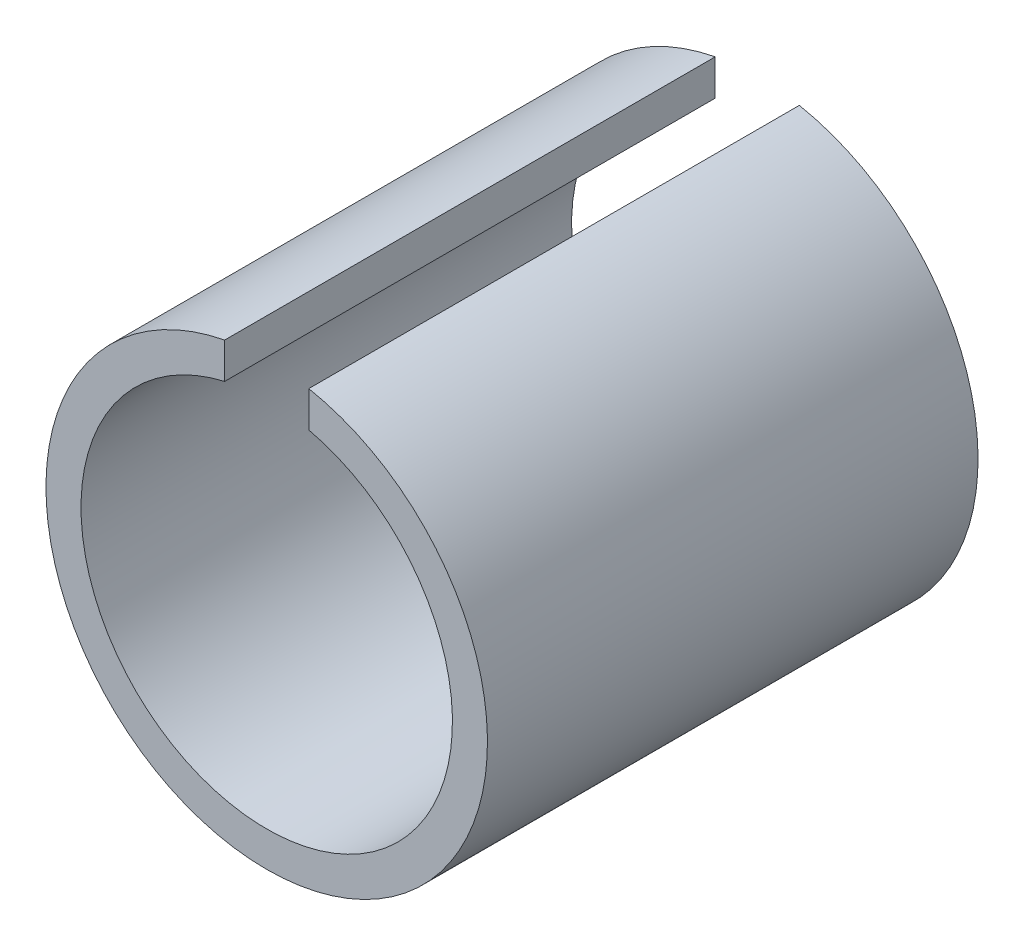
from build123d import *

# Parameters (mm, degrees)
BOSS_EXTRUDE1_DEPTH = 7


with BuildPart() as part:
    # Sketch1 → Boss-Extrude1 (new body)
    with BuildSketch(Plane.XY):
        with BuildLine():
            Line((-0.6, 3.092329219), (-0.6, 2.5811819))
            ThreePointArc((-0.6, 2.5811819), (0, -2.65), (0.6, 2.5811819))
            Line((0.6, 2.5811819), (0.6, 3.092329219))
            ThreePointArc((0.6, 3.092329219), (0, -3.15), (-0.6, 3.092329219))
        make_face()
    extrude(amount=BOSS_EXTRUDE1_DEPTH)


solid = part.part
